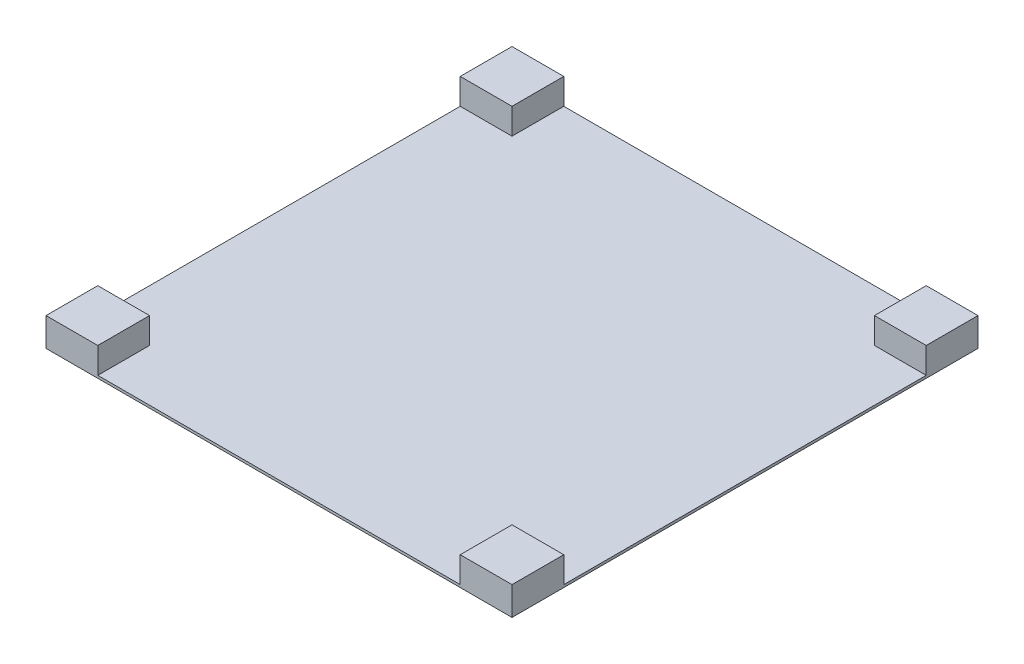
from build123d import *

# Parameters (mm, degrees)
SKETCH2_W           = 900
SKETCH2_H           = 900
BOSS_EXTRUDE2_DEPTH = 5
SKETCH4_W           = 100
SKETCH4_H           = 100
BOSS_EXTRUDE3_DEPTH = 50


with BuildPart() as part:
    # Sketch2 → Boss-Extrude2 (new body)
    with BuildSketch(Plane(origin=(0, 0, 0), x_dir=(1, 0, 0), z_dir=(0, 1, 0))):
        Rectangle(SKETCH2_W, SKETCH2_H)
    extrude(amount=BOSS_EXTRUDE2_DEPTH)

    # Sketch4 → Boss-Extrude3 (add)
    with BuildSketch(Plane(origin=(0, 5, 0), x_dir=(1, 0, 0), z_dir=(0, 1, 0))):
        with Locations((-400, 400)):
            Rectangle(SKETCH4_W, SKETCH4_H)
        with Locations((400, 400)):
            Rectangle(SKETCH4_W, SKETCH4_H)
        with Locations((400, -400)):
            Rectangle(SKETCH4_W, SKETCH4_H)
        with Locations((-400, -400)):
            Rectangle(SKETCH4_W, SKETCH4_H)
    extrude(amount=BOSS_EXTRUDE3_DEPTH)


solid = part.part
